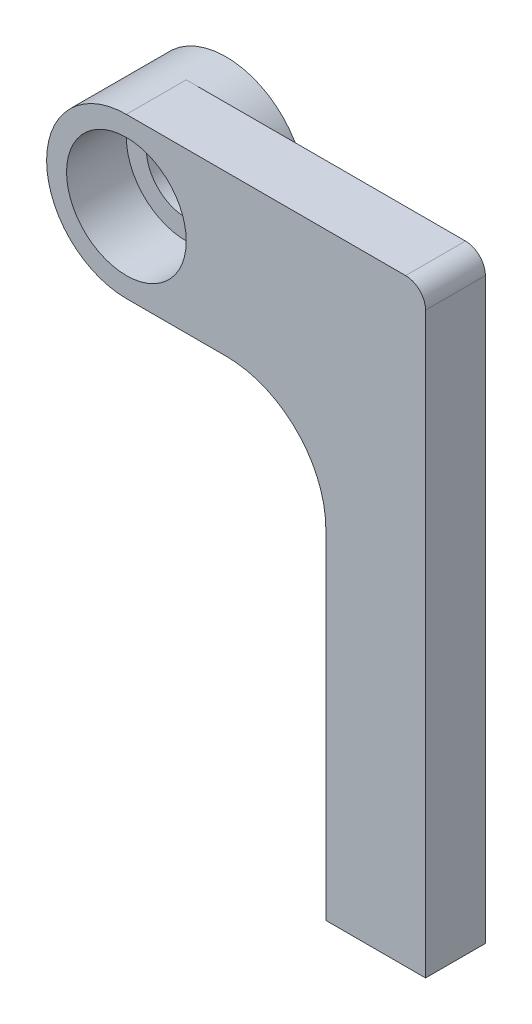
from build123d import *

# Parameters (mm, degrees)
BOSS_EXTRUDE1_DEPTH = 3
SKETCH2_R           = 3
CUT_EXTRUDE1_DEPTH  = 5
FILLET1_R           = 5
FILLET3_R           = 1
SKETCH4_R           = 4
SKETCH4_R_2         = 2
BOSS_EXTRUDE2_DEPTH = 2


with BuildPart() as part:
    # Sketch1 → Boss-Extrude1 (new body)
    with BuildSketch(Plane.XY):
        with BuildLine():
            Line((0, -4), (10, -4))
            Line((10, -4), (10, -26))
            Line((10, -26), (15, -26))
            Line((15, -26), (15, 4))
            Line((15, 4), (10, 4))
            Line((10, 4), (0, 4))
            ThreePointArc((0, 4), (-4, 0), (0, -4))
        make_face()
    extrude(amount=BOSS_EXTRUDE1_DEPTH)

    # Sketch2 → Cut-Extrude1 (cut)
    with BuildSketch(Plane(origin=(0, 0, 0), x_dir=(-1, 0, 0), z_dir=(0, 0, -1))):
        Circle(SKETCH2_R)
    extrude(amount=-CUT_EXTRUDE1_DEPTH, mode=Mode.SUBTRACT)

    # Fillet1
    fillet1_edges = [part.edges().sort_by_distance(p)[0] for p in [
        (10, -4, 1.5),
    ]]
    fillet(fillet1_edges, radius=FILLET1_R)

    # Fillet3
    fillet3_edges = [part.edges().sort_by_distance(p)[0] for p in [
        (15, 4, 1.5),
    ]]
    fillet(fillet3_edges, radius=FILLET3_R)

    # Sketch4 → Boss-Extrude2 (add)
    with BuildSketch(Plane(origin=(0, 0, 0), x_dir=(-1, 0, 0), z_dir=(0, 0, -1))):
        Circle(SKETCH4_R)
        Circle(SKETCH4_R_2, mode=Mode.SUBTRACT)
    extrude(amount=BOSS_EXTRUDE2_DEPTH)


solid = part.part
